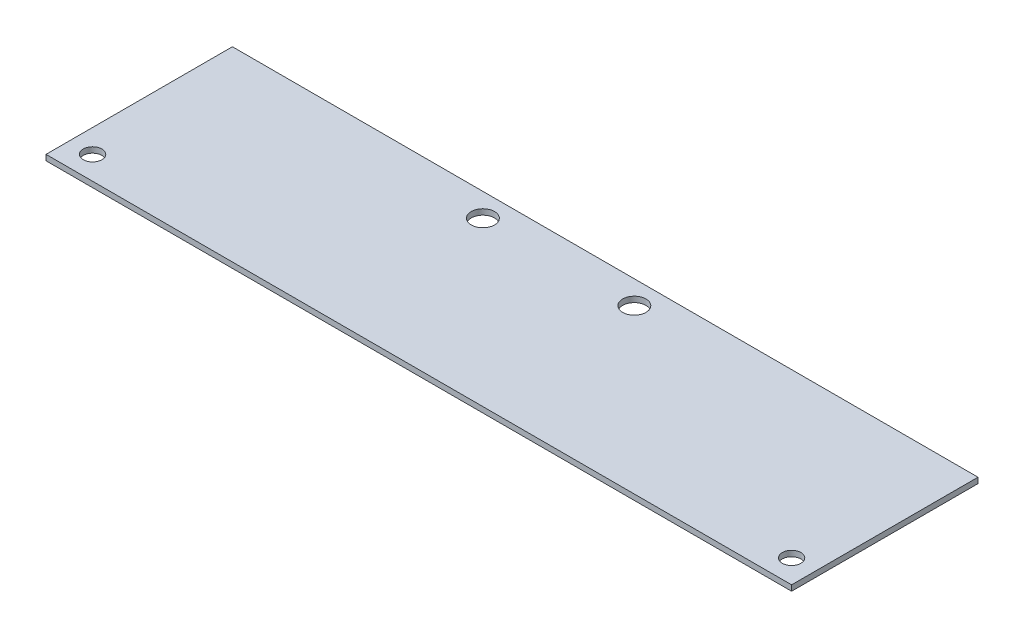
from build123d import *

# Parameters (mm, degrees)
SKETCH1_W           = 203.2
SKETCH1_H           = 50.8
SKETCH1_R           = 2.54
SKETCH1_R_2         = 3.175
BOSS_EXTRUDE1_DEPTH = 1.524


with BuildPart() as part:
    # Sketch1 → Boss-Extrude1 (new body)
    with BuildSketch(Plane(origin=(0, 0, 0), x_dir=(1, 0, 0), z_dir=(0, 1, 0))):
        with Locations((101.6, 25.4)):
            Rectangle(SKETCH1_W, SKETCH1_H)
        with Locations((6.35, 6.35)):
            Circle(SKETCH1_R, mode=Mode.SUBTRACT)
        with Locations((196.85, 6.35)):
            Circle(SKETCH1_R, mode=Mode.SUBTRACT)
        with Locations((74.6125, 44.45)):
            Circle(SKETCH1_R_2, mode=Mode.SUBTRACT)
        with Locations((115.8875, 44.45)):
            Circle(SKETCH1_R_2, mode=Mode.SUBTRACT)
    extrude(amount=BOSS_EXTRUDE1_DEPTH)


solid = part.part
